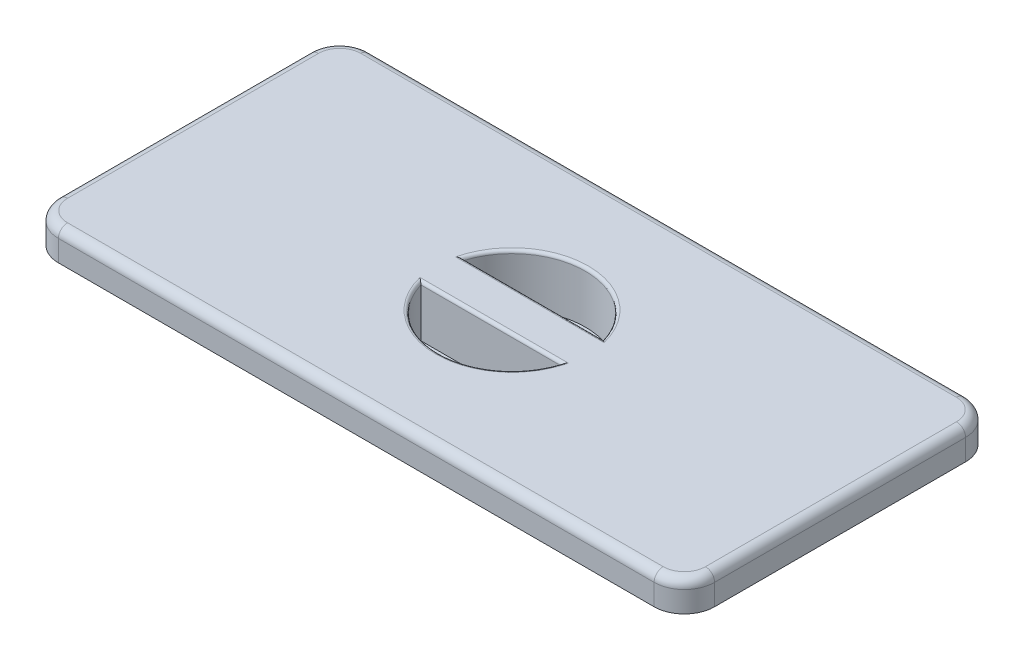
from build123d import *

# Parameters (mm, degrees)
SKETCH1_W           = 217
SKETCH1_H           = 103
BOSS_EXTRUDE1_DEPTH = 10
FILLET1_R           = 10
SHELL1_T            = -4
FILLET2_R           = 3
BOSS_EXTRUDE3_DEPTH = 16
CUT_EXTRUDE2_DEPTH  = 17
FILLET3_R           = 1
FILLET4_R           = 1
BOSS_EXTRUDE4_DEPTH = 8
FILLET5_R           = 3


with BuildPart() as part:
    # Sketch1 → Boss-Extrude1 (new body)
    with BuildSketch(Plane(origin=(0, 0, 0), x_dir=(1, 0, 0), z_dir=(0, 1, 0))):
        Rectangle(SKETCH1_W, SKETCH1_H)
    extrude(amount=BOSS_EXTRUDE1_DEPTH)

    # Fillet1
    fillet1_edges = [part.edges().sort_by_distance(p)[0] for p in [
        (108.5, 5, 51.5),
        (-108.5, 5, 51.5),
        (-108.5, 5, -51.5),
        (108.5, 5, -51.5),
    ]]
    fillet(fillet1_edges, radius=FILLET1_R)

    # Shell1
    shell1_openings = [part.faces().sort_by_distance(p)[0] for p in [
        (0, 0, 0),
    ]]
    offset(amount=SHELL1_T, openings=shell1_openings, kind=Kind.INTERSECTION)

    # Fillet2
    fillet2_edges = [part.edges().sort_by_distance(p)[0] for p in [
        (108.5, 10, 0),
        (0, 10, 51.5),
        (0, 10, -51.5),
        (-108.5, 10, 0),
        (-105.571067812, 10, 48.571067812),
        (-105.571067812, 10, -48.571067812),
        (105.571067812, 10, -48.571067812),
        (105.571067812, 10, 48.571067812),
    ]]
    fillet(fillet2_edges, radius=FILLET2_R)

    # Sketch4 → Boss-Extrude3 (add)
    with BuildSketch(Plane.XZ.offset(-6)):
        with BuildLine():
            Line((-27.70479426, 3.5), (27.70479426, 3.5))
            ThreePointArc((27.70479426, 3.5), (0, 27.925), (-27.70479426, 3.5))
        make_face()
        with BuildLine():
            Line((-27.70479426, -3.5), (27.70479426, -3.5))
            ThreePointArc((27.70479426, -3.5), (0, -27.925), (-27.70479426, -3.5))
        make_face()
    extrude(amount=BOSS_EXTRUDE3_DEPTH)

    # Sketch2 → Cut-Extrude2 (cut)
    with BuildSketch(Plane(origin=(0, 10, 0), x_dir=(1, 0, 0), z_dir=(0, 1, 0))):
        with BuildLine():
            Line((-23.255039776, 6.875), (23.255039776, 6.875))
            ThreePointArc((23.255039776, 6.875), (0, 24.25), (-23.255039776, 6.875))
        make_face()
        with BuildLine():
            Line((-23.255039776, -6.875), (23.255039776, -6.875))
            ThreePointArc((23.255039776, -6.875), (0, -24.25), (-23.255039776, -6.875))
        make_face()
    extrude(amount=-CUT_EXTRUDE2_DEPTH, mode=Mode.SUBTRACT)

    # Fillet3
    fillet3_edges = [part.edges().sort_by_distance(p)[0] for p in [
        (0, 10, -6.875),
        (0, 10, 24.25),
        (0, 10, 6.875),
        (0, 10, -24.25),
    ]]
    fillet(fillet3_edges, radius=FILLET3_R)

    # Fillet4
    fillet4_edges = [part.edges().sort_by_distance(p)[0] for p in [
        (0, -10, 3.5),
        (-27.70479426, -2, 3.5),
        (0, 6, 3.5),
        (0, -10, 27.925),
        (27.70479426, -2, 3.5),
        (0, 6, 27.925),
        (0, -10, -3.5),
        (27.70479426, -2, -3.5),
        (0, 6, -3.5),
        (0, -10, -27.925),
        (-27.70479426, -2, -3.5),
        (0, 6, -27.925),
    ]]
    fillet(fillet4_edges, radius=FILLET4_R)

    # Sketch5 → Boss-Extrude4 (add)
    with BuildSketch(Plane.XZ.offset(-6)):
        Polygon((-92.5, 36.425), (92.5, 36.425), (92.5, 7.375), (90.89, 7.375), (90.89, 34.325), (-90.89, 34.325), (-90.89, -34.325), (90.89, -34.325), (90.89, -7.375), (92.5, -7.375), (92.5, -36.425), (-92.5, -36.425), align=None)
    extrude(amount=BOSS_EXTRUDE4_DEPTH)

    # Fillet5
    fillet5_edges = [part.edges().sort_by_distance(p)[0] for p in [
        (-92.5, 2, 36.425),
        (-92.5, 2, -36.425),
        (92.5, 2, -36.425),
        (90.89, 2, -34.325),
        (-90.89, 2, -34.325),
        (-90.89, 2, 34.325),
        (90.89, 2, 34.325),
        (92.5, 2, 36.425),
    ]]
    fillet(fillet5_edges, radius=FILLET5_R)


solid = part.part
